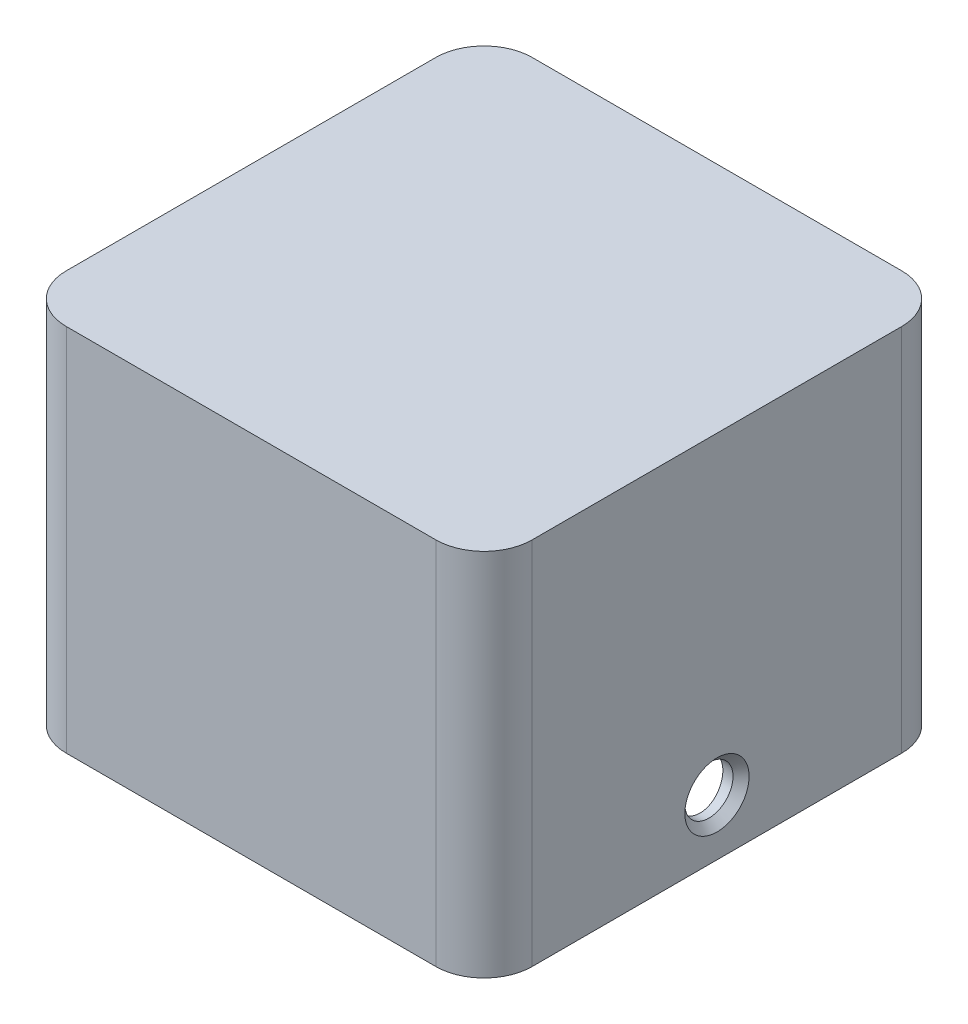
from build123d import *

# Parameters (mm, degrees)
SKETCH1_W           = 29
SKETCH1_H           = 29
BOSS_EXTRUDE1_DEPTH = 23
FILLET1_R           = 3
SKETCH2_R           = 13.45
CUT_EXTRUDE1_DEPTH  = 6.75
SKETCH7_R           = 0.85
CUT_EXTRUDE2_DEPTH  = 10
SKETCH8_R           = 1.5
CUT_EXTRUDE3_DEPTH  = 30
CHAMFER1_SIZE       = 0.5


with BuildPart() as part:
    # Sketch1 → Boss-Extrude1 (new body)
    with BuildSketch(Plane(origin=(0, 0, 0), x_dir=(1, 0, 0), z_dir=(0, 1, 0))):
        with Locations((14.5, 14.5)):
            Rectangle(SKETCH1_W, SKETCH1_H)
    extrude(amount=BOSS_EXTRUDE1_DEPTH)

    # Fillet1
    fillet1_edges = [part.edges().sort_by_distance(p)[0] for p in [
        (0, 11.5, -29),
        (29, 11.5, -29),
        (29, 11.5, 0),
        (0, 11.5, 0),
    ]]
    fillet(fillet1_edges, radius=FILLET1_R)

    # Sketch2 → Cut-Extrude1 (cut)
    with BuildSketch(Plane.XZ):
        with Locations((14.5, -14.5)):
            Circle(SKETCH2_R)
    extrude(amount=-CUT_EXTRUDE1_DEPTH, mode=Mode.SUBTRACT)

    # Sketch6 → Cut-Revolve1 (revolve, cut)
    with BuildSketch(Plane(origin=(14.5, 0, 0), x_dir=(0, 0, -1), z_dir=(1, 0, 0))):
        with BuildLine():
            Line((14.5, 6.75), (14.5, 19.6))
            ThreePointArc((14.5, 19.6), (23.586322138, 15.836322138), (27.35, 6.75))
            Line((27.35, 6.75), (14.5, 6.75))
        make_face()
    revolve(axis=Axis((14.5, 6.75, -14.5), (0, 1, 0)), mode=Mode.SUBTRACT)

    # Sketch7 → Cut-Extrude2 (cut)
    with BuildSketch(Plane.XZ):
        with Locations((3, -3)):
            Circle(SKETCH7_R)
        with Locations((26, -3)):
            Circle(SKETCH7_R)
        with Locations((26, -26)):
            Circle(SKETCH7_R)
        with Locations((3, -26)):
            Circle(SKETCH7_R)
    extrude(amount=-CUT_EXTRUDE2_DEPTH, mode=Mode.SUBTRACT)

    # Sketch8 → Cut-Extrude3 (cut, through all)
    with BuildSketch(Plane.ZY):
        with Locations((-14.5, 3.5)):
            Circle(SKETCH8_R)
    extrude(amount=-CUT_EXTRUDE3_DEPTH, mode=Mode.SUBTRACT)

    # Chamfer1
    chamfer1_edges = [part.edges().sort_by_distance(p)[0] for p in [
        (29, 3.5, -16),
        (0, 3.5, -16),
    ]]
    chamfer(chamfer1_edges, length=CHAMFER1_SIZE)


solid = part.part
